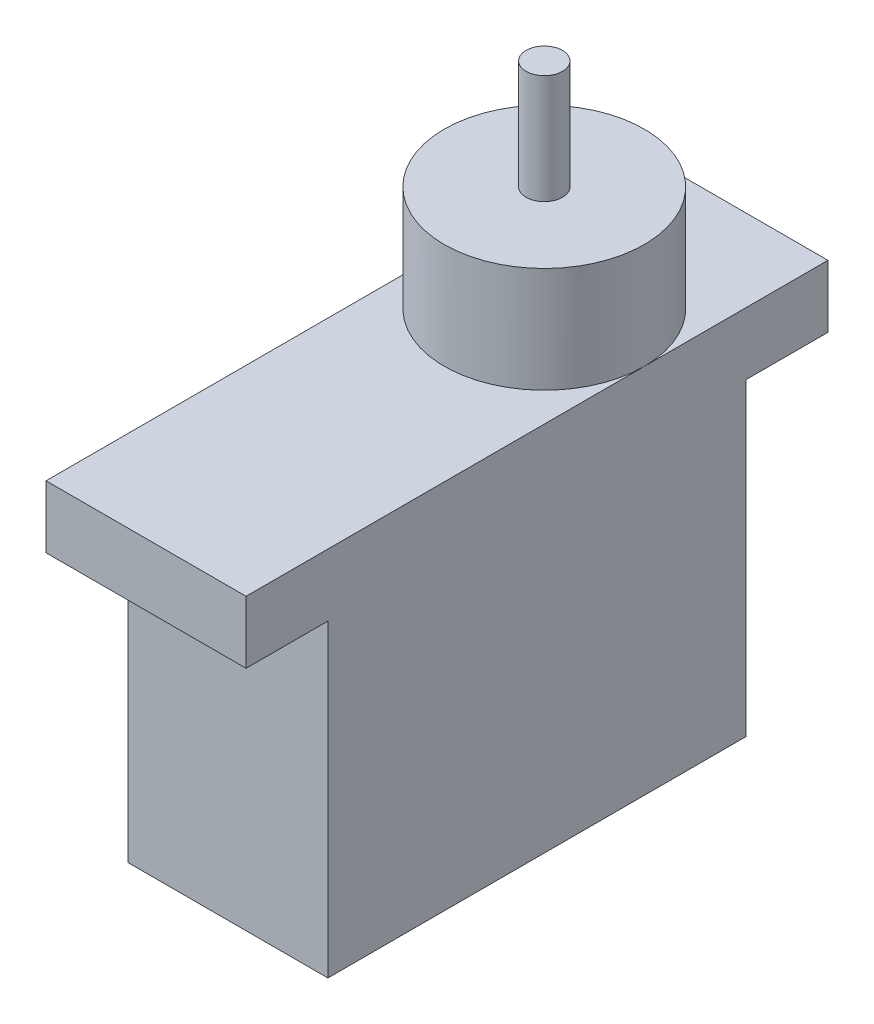
from build123d import *

# Parameters (mm, degrees)
BOSS_EXTRU_1_DEPTH = 11
ESQUISSE2_R        = 5.5
BOSS_EXTRU_2_DEPTH = 5.8
ESQUISSE7_R        = 1
BOSS_EXTRU_3_DEPTH = 6


with BuildPart() as part:
    # Esquisse1 → Boss.-Extru.1 (new body)
    with BuildSketch(Plane(origin=(0, 0, 0), x_dir=(0, 0, -1), z_dir=(1, 0, 0))):
        Polygon((0, 17), (4.5, 17), (4.5, 20.43), (-27.5, 20.43), (-27.5, 17), (-23, 17), (-23, 0), (0, 0), align=None)
    extrude(amount=BOSS_EXTRU_1_DEPTH)

    # Esquisse2 → Boss.-Extru.2 (add)
    with BuildSketch(Plane(origin=(0, 20.43, 0), x_dir=(1, 0, 0), z_dir=(0, 1, 0))):
        with Locations((5.5, -5.6)):
            Circle(ESQUISSE2_R)
    extrude(amount=BOSS_EXTRU_2_DEPTH)

    # Esquisse7 → Boss.-Extru.3 (add)
    with BuildSketch(Plane(origin=(0, 26.23, 0), x_dir=(1, 0, 0), z_dir=(0, 1, 0))):
        with Locations((5.5, -5.6)):
            Circle(ESQUISSE7_R)
    extrude(amount=BOSS_EXTRU_3_DEPTH)


solid = part.part
